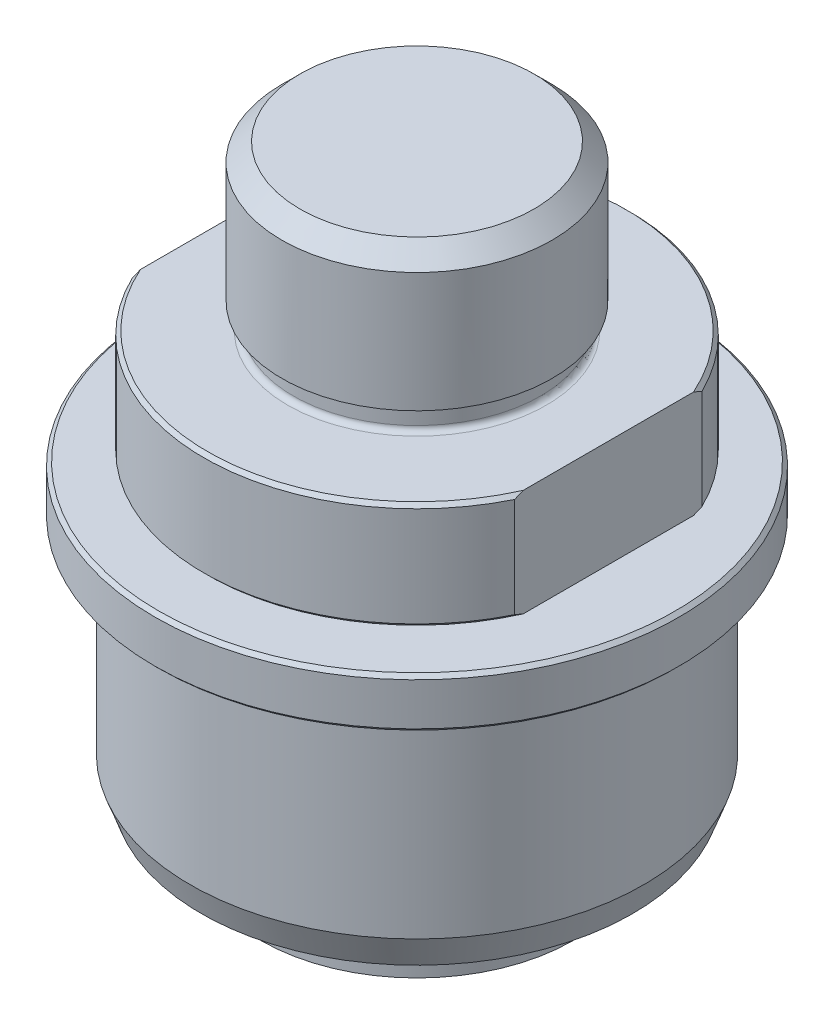
from build123d import *

# Parameters (mm, degrees)
CHAMFER1_SIZE      = 0.508
CHAMFER2_SIZE      = 2.54
CUT_EXTRUDE1_DEPTH = 64.5254
CHAMFER3_SIZE      = 0.508
SKETCH3_R          = 1.2192
REVOLVE3_ANGLE     = 330


with BuildPart() as part:
    # Sketch1 → Revolve1 (revolve)
    with BuildSketch(Plane.XY, mode=Mode.PRIVATE) as revolve1_sk:
        with BuildLine():
            Line((0, 23.114), (0, -36.6268))
            Line((0, -36.6268), (4.699, -36.6268))
            Line((4.699, -36.6268), (15.0876, -47.0154))
            Line((15.0876, -47.0154), (15.0876, -62.0014))
            ThreePointArc((15.0876, -62.0014), (15.533969265, -63.079030735), (16.6116, -63.5254))
            Line((16.6116, -63.5254), (21.971, -63.5254))
            Line((21.971, -63.5254), (21.971, -60.833))
            ThreePointArc((21.971, -60.833), (20.701, -59.563), (21.971, -58.293))
            Line((21.971, -58.293), (21.971, -15.0876))
            Line((21.971, -15.0876), (30.0482, -15.0876))
            Line((30.0482, -15.0876), (30.0482, 0))
            Line((30.0482, 0), (18.2245, 0))
            ThreePointArc((18.2245, 0), (17.685684633, 0.223184633), (17.4625, 0.762))
            Line((17.4625, 0.762), (17.4625, 3.683))
            Line((17.4625, 3.683), (19.05, 3.683))
            Line((19.05, 3.683), (19.05, 23.114))
            Line((19.05, 23.114), (0, 23.114))
        make_face()
    revolve(revolve1_sk.sketch.rotate(Axis((0, 23.114, 0), (0, 1, 0)), 90), axis=Axis((0, 23.114, 0), (0, 1, 0)))  # turned: the seam where the file's is

    # Chamfer1
    chamfer1_edges = [part.edges().sort_by_distance(p)[0] for p in [
        (0, -15.0876, 30.0482),
        (0, 0, 30.0482),
    ]]
    chamfer(chamfer1_edges, length=CHAMFER1_SIZE)

    # Chamfer2
    chamfer2_edges = [part.edges().sort_by_distance(p)[0] for p in [
        (0, 23.114, 19.05),
    ]]
    chamfer(chamfer2_edges, length=CHAMFER2_SIZE)

    # Sketch4 → Cut-Extrude1 (cut, through all)
    with BuildSketch(Plane(origin=(0, 0, 0), x_dir=(1, 0, 0), z_dir=(0, 1, 0))):
        with BuildLine():
            Line((-26.9875, 13.212462563), (-26.9875, -13.212462563))
            ThreePointArc((-26.9875, -13.212462563), (-30.0482, 0), (-26.9875, 13.212462563))
        make_face()
        with BuildLine():
            Line((26.9875, 13.212462563), (26.9875, -13.212462563))
            ThreePointArc((26.9875, -13.212462563), (30.0482, 0), (26.9875, 13.212462563))
        make_face()
    extrude(amount=-CUT_EXTRUDE1_DEPTH, mode=Mode.SUBTRACT)


with BuildPart() as body_2:
    # Sketch2 → Revolve2 (revolve)
    with BuildSketch(Plane.XY, mode=Mode.PRIVATE) as revolve2_sk:
        with BuildLine():
            Line((22.0218, -16.002), (22.0218, -50.6476))
            Line((22.0218, -50.6476), (24.0157, -50.6476))
            ThreePointArc((24.0157, -50.6476), (24.73412049, -50.94517951), (25.0317, -51.6636))
            Line((25.0317, -51.6636), (25.0317, -56.007))
            Line((25.0317, -56.007), (30.406976528, -56.007))
            Line((30.406976528, -56.007), (31.9786, -51.689))
            Line((31.9786, -51.689), (31.9786, -23.7744))
            ThreePointArc((31.9786, -23.7744), (32.201784633, -23.235584633), (32.7406, -23.0124))
            Line((32.7406, -23.0124), (36.957, -23.0124))
            Line((36.957, -23.0124), (36.957, -16.002))
            Line((36.957, -16.002), (22.0218, -16.002))
        make_face()
    revolve(revolve2_sk.sketch.rotate(Axis((0, 0, 0), (0, 1, 0)), 90), axis=Axis((0, 0, 0), (0, 1, 0)))  # turned: the seam where the file's is

    # Chamfer3
    chamfer3_edges = [body_2.edges().sort_by_distance(p)[0] for p in [
        (0, -16.002, 36.957),
        (0, -23.0124, 36.957),
    ]]
    chamfer(chamfer3_edges, length=CHAMFER3_SIZE)


with BuildPart() as body_3:
    # Sketch3 → Revolve3 (revolve)
    with BuildSketch(Plane.XY):
        with Locations((21.971, -59.563)):
            Circle(SKETCH3_R)
    revolve(axis=Axis((0, 0, 0), (0, -1, 0)), revolution_arc=REVOLVE3_ANGLE)


solid = Compound([part.part, body_2.part, body_3.part])
